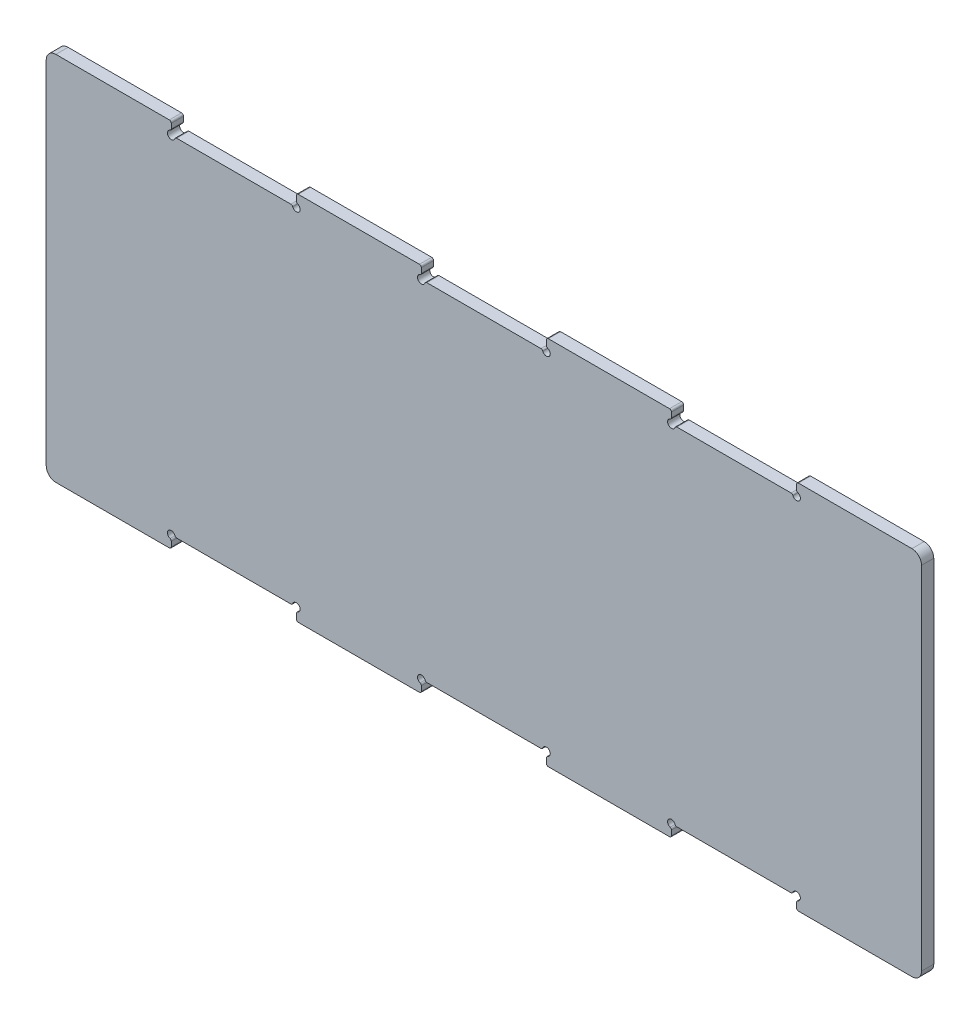
from build123d import *

# Parameters (mm, degrees)
SKETCH1_W               = 455
SKETCH1_H               = 180
BOSS_EXTRUDE1_DEPTH     = 3.175
SKETCH2_W               = 65
SKETCH2_H               = 6.35
BOSS_EXTRUDE2_DEPTH     = 6.35
LPATTERN1_COUNT         = 4
LPATTERN1_PITCH         = 130
MIRROR1_COPY_1_SKETCH_W = 65
MIRROR1_COPY_1_SKETCH_H = 6.35
MIRROR1_COPY_1_DEPTH    = 6.35
MIRROR1_COPY_2_SKETCH_W = 65
MIRROR1_COPY_2_SKETCH_H = 6.35
MIRROR1_COPY_2_DEPTH    = 6.35
MIRROR1_COPY_3_SKETCH_W = 65
MIRROR1_COPY_3_SKETCH_H = 6.35
MIRROR1_COPY_3_DEPTH    = 6.35
SKETCH3_R               = 2
CUT_EXTRUDE1_DEPTH      = 7.35
FILLET2_R               = 1
CUT_EXTRUDE2_DEPTH      = 7.35
LPATTERN2_COUNT         = 3
LPATTERN2_PITCH         = 130
MIRROR2_COPY_1_DEPTH    = 7.35
MIRROR2_COPY_2_DEPTH    = 7.35
FILLET4_R               = 5


with BuildPart() as part:
    # Sketch1 → Boss-Extrude1 (new body, symmetric)
    with BuildSketch(Plane.XY):
        with Locations((227.5, 90)):
            Rectangle(SKETCH1_W, SKETCH1_H)
    extrude(amount=BOSS_EXTRUDE1_DEPTH, both=True)

    # Sketch2 → Boss-Extrude2 (add)
    with BuildSketch(Plane.XY.offset(3.175)):
        with Locations((422.5, -3.175)):
            Rectangle(SKETCH2_W, SKETCH2_H)
    boss_extrude2 = extrude(amount=-BOSS_EXTRUDE2_DEPTH)

    # LPattern1: Boss-Extrude2 ×4
    with Locations(*[(-i * LPATTERN1_PITCH, 0, 0) for i in range(1, LPATTERN1_COUNT)]):
        add(boss_extrude2)

    # Mirror1: Boss-Extrude2 across plane
    add(boss_extrude2.mirror(Plane(origin=(0, 90, 0), x_dir=(0, 0, 1), z_dir=(0, -1, 0))))

    # Mirror1 copy 1 sketch → Mirror1 copy 1 (add)
    with BuildSketch(Plane(origin=(-130, 180, 3.175), x_dir=(1, 0, 0), z_dir=(0, 0, 1))):
        with Locations((422.5, 3.175)):
            Rectangle(MIRROR1_COPY_1_SKETCH_W, MIRROR1_COPY_1_SKETCH_H)
    extrude(amount=-MIRROR1_COPY_1_DEPTH)

    # Mirror1 copy 2 sketch → Mirror1 copy 2 (add)
    with BuildSketch(Plane(origin=(-260, 180, 3.175), x_dir=(1, 0, 0), z_dir=(0, 0, 1))):
        with Locations((422.5, 3.175)):
            Rectangle(MIRROR1_COPY_2_SKETCH_W, MIRROR1_COPY_2_SKETCH_H)
    extrude(amount=-MIRROR1_COPY_2_DEPTH)

    # Mirror1 copy 3 sketch → Mirror1 copy 3 (add)
    with BuildSketch(Plane(origin=(-390, 180, 3.175), x_dir=(1, 0, 0), z_dir=(0, 0, 1))):
        with Locations((422.5, 3.175)):
            Rectangle(MIRROR1_COPY_3_SKETCH_W, MIRROR1_COPY_3_SKETCH_H)
    extrude(amount=-MIRROR1_COPY_3_DEPTH)

    # Sketch3 → Cut-Extrude1 (cut, through all)
    with BuildSketch(Plane.XY.offset(3.175)):
        with Locations((325, 0)):
            Circle(SKETCH3_R)
        with Locations((390, 0)):
            Circle(SKETCH3_R)
    extrude(amount=-CUT_EXTRUDE1_DEPTH, mode=Mode.SUBTRACT)

    # Fillet2
    fillet2_edges = [part.edges().sort_by_distance(p)[0] for p in [
        (390, -6.35, 0),
        (325, -6.35, 0),
    ]]
    fillet(fillet2_edges, radius=FILLET2_R)

    # Sketch4 → Cut-Extrude2 (cut, through all)
    with BuildSketch(Plane.XY.offset(3.175)):
        with BuildLine():
            Line((390, -2.828427125), (390, -5.35))
            ThreePointArc((390, -5.35), (390.292893219, -6.057106781), (391, -6.35))
            Line((391, -6.35), (324, -6.35))
            ThreePointArc((324, -6.35), (324.707106781, -6.057106781), (325, -5.35))
            Line((325, -5.35), (325, -2.828427125))
            ThreePointArc((325, -2.828427125), (324.816496581, -2.251076856), (324.333333333, -1.885618083))
            ThreePointArc((324.333333333, -1.885618083), (323.585786438, 1.414213562), (326.885618083, 0.666666667))
            ThreePointArc((326.885618083, 0.666666667), (327.251076856, 0.183503419), (327.828427125, 0))
            Line((327.828427125, 0), (387.171572875, 0))
            ThreePointArc((387.171572875, 0), (387.748923144, 0.183503419), (388.114381917, 0.666666667))
            ThreePointArc((388.114381917, 0.666666667), (391.414213562, 1.414213562), (390.666666667, -1.885618083))
            ThreePointArc((390.666666667, -1.885618083), (390.183503419, -2.251076856), (390, -2.828427125))
        make_face()
    cut_extrude2 = extrude(amount=-CUT_EXTRUDE2_DEPTH, mode=Mode.SUBTRACT)

    # LPattern2: Cut-Extrude2 ×3
    with Locations(*[(-i * LPATTERN2_PITCH, 0, 0) for i in range(1, LPATTERN2_COUNT)]):
        add(cut_extrude2, mode=Mode.SUBTRACT)

    # Mirror2: Cut-Extrude2 across plane
    add(cut_extrude2.mirror(Plane(origin=(0, 90, 0), x_dir=(0, 0, 1), z_dir=(0, -1, 0))), mode=Mode.SUBTRACT)

    # Mirror2 copy 1 sketch → Mirror2 copy 1 (cut, through all)
    with BuildSketch(Plane(origin=(-130, 180, 3.175), x_dir=(1, 0, 0), z_dir=(0, 0, 1))):
        with BuildLine():
            Line((390, 2.828427125), (390, 5.35))
            ThreePointArc((390, 5.35), (390.292893219, 6.057106781), (391, 6.35))
            Line((391, 6.35), (324, 6.35))
            ThreePointArc((324, 6.35), (324.707106781, 6.057106781), (325, 5.35))
            Line((325, 5.35), (325, 2.828427125))
            ThreePointArc((325, 2.828427125), (324.816496581, 2.251076856), (324.333333333, 1.885618083))
            ThreePointArc((324.333333333, 1.885618083), (323.585786438, -1.414213562), (326.885618083, -0.666666667))
            ThreePointArc((326.885618083, -0.666666667), (327.251076856, -0.183503419), (327.828427125, 0))
            Line((327.828427125, 0), (387.171572875, 0))
            ThreePointArc((387.171572875, 0), (387.748923144, -0.183503419), (388.114381917, -0.666666667))
            ThreePointArc((388.114381917, -0.666666667), (391.414213562, -1.414213562), (390.666666667, 1.885618083))
            ThreePointArc((390.666666667, 1.885618083), (390.183503419, 2.251076856), (390, 2.828427125))
        make_face()
    extrude(amount=-MIRROR2_COPY_1_DEPTH, mode=Mode.SUBTRACT)

    # Mirror2 copy 2 sketch → Mirror2 copy 2 (cut, through all)
    with BuildSketch(Plane(origin=(-260, 180, 3.175), x_dir=(1, 0, 0), z_dir=(0, 0, 1))):
        with BuildLine():
            Line((390, 2.828427125), (390, 5.35))
            ThreePointArc((390, 5.35), (390.292893219, 6.057106781), (391, 6.35))
            Line((391, 6.35), (324, 6.35))
            ThreePointArc((324, 6.35), (324.707106781, 6.057106781), (325, 5.35))
            Line((325, 5.35), (325, 2.828427125))
            ThreePointArc((325, 2.828427125), (324.816496581, 2.251076856), (324.333333333, 1.885618083))
            ThreePointArc((324.333333333, 1.885618083), (323.585786438, -1.414213562), (326.885618083, -0.666666667))
            ThreePointArc((326.885618083, -0.666666667), (327.251076856, -0.183503419), (327.828427125, 0))
            Line((327.828427125, 0), (387.171572875, 0))
            ThreePointArc((387.171572875, 0), (387.748923144, -0.183503419), (388.114381917, -0.666666667))
            ThreePointArc((388.114381917, -0.666666667), (391.414213562, -1.414213562), (390.666666667, 1.885618083))
            ThreePointArc((390.666666667, 1.885618083), (390.183503419, 2.251076856), (390, 2.828427125))
        make_face()
    extrude(amount=-MIRROR2_COPY_2_DEPTH, mode=Mode.SUBTRACT)

    # Fillet4
    fillet4_edges = [part.edges().sort_by_distance(p)[0] for p in [
        (455, -6.35, 0),
        (0, -6.35, 0),
        (455, 186.35, 0),
        (0, 186.35, 0),
    ]]
    fillet(fillet4_edges, radius=FILLET4_R)


solid = part.part
